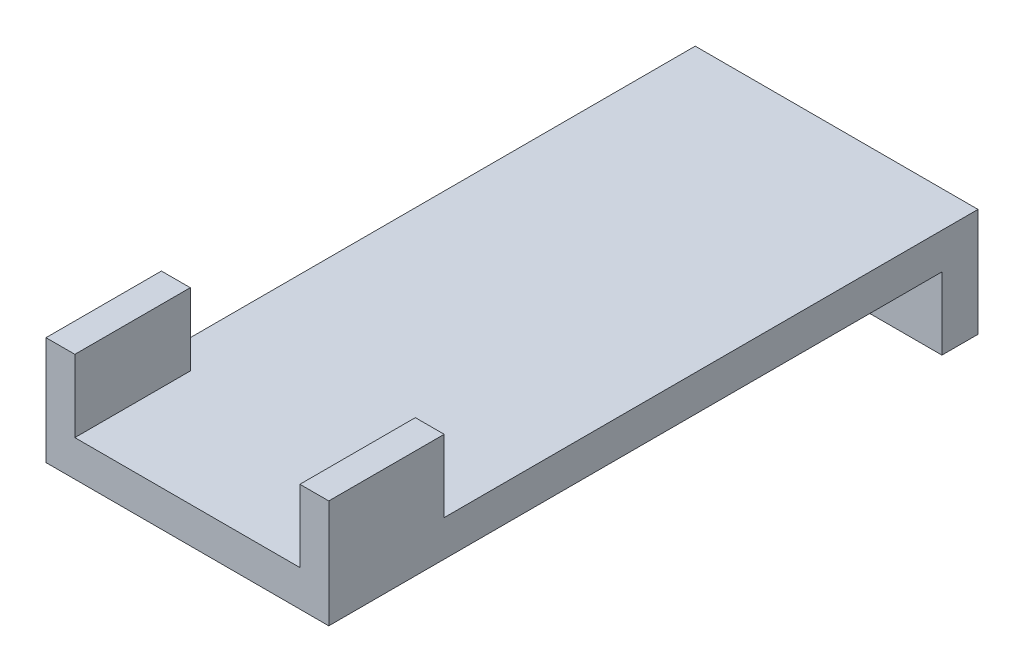
from build123d import *

# Parameters (mm, degrees)
SKETCH2_W           = 24.892
SKETCH2_H           = 57.15
BOSS_EXTRUDE1_DEPTH = 3.175
SKETCH3_W           = 2.54
SKETCH3_H           = 10.16
BOSS_EXTRUDE2_DEPTH = 6.35
SKETCH4_W           = 24.892
SKETCH4_H           = 3.175
BOSS_EXTRUDE3_DEPTH = 6.35
SCALE1_SCALE        = 1.02


with BuildPart() as part:
    # Sketch2 → Boss-Extrude1 (new body)
    with BuildSketch(Plane(origin=(0, 0, 0), x_dir=(1, 0, 0), z_dir=(0, 1, 0))):
        Rectangle(SKETCH2_W, SKETCH2_H)
    extrude(amount=BOSS_EXTRUDE1_DEPTH)

    # Sketch3 → Boss-Extrude2 (add)
    with BuildSketch(Plane(origin=(0, 3.175, 0), x_dir=(1, 0, 0), z_dir=(0, 1, 0))):
        with Locations((11.176, -23.495)):
            Rectangle(SKETCH3_W, SKETCH3_H)
        with Locations((-11.176, -23.495)):
            Rectangle(SKETCH3_W, SKETCH3_H)
    extrude(amount=BOSS_EXTRUDE2_DEPTH)

    # Sketch4 → Boss-Extrude3 (add)
    with BuildSketch(Plane.XZ):
        with Locations((0, -26.9875)):
            Rectangle(SKETCH4_W, SKETCH4_H)
    extrude(amount=BOSS_EXTRUDE3_DEPTH)


with BuildPart() as part_1:
    # Scale1: scaled about (0, 1.432399425, -1.093002874)
    add(part.part.scale(SCALE1_SCALE).moved(Location((0, -0.028647989, 0.021860057))))


solid = part_1.part
